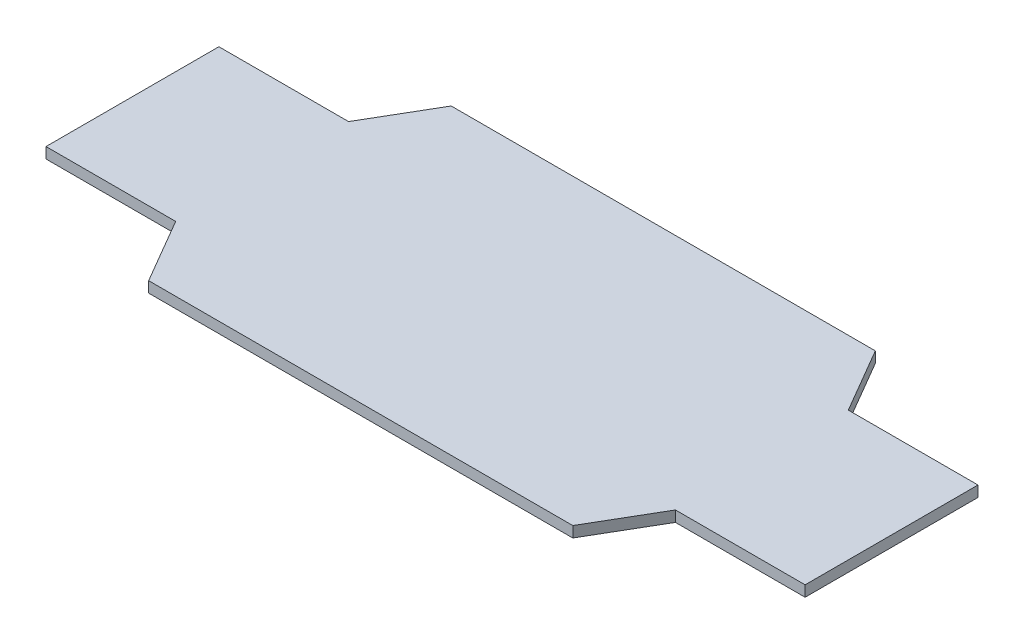
from build123d import *

# Parameters (mm, degrees)
BOSS_EXTRUDE1_DEPTH = 5.08


with BuildPart() as part:
    # Sketch1 → Boss-Extrude1 (new body)
    with BuildSketch(Plane(origin=(0, 0, 0), x_dir=(1, 0, 0), z_dir=(0, 1, 0))):
        Polygon((178.435, 40.64), (117.475, 40.64), (99.695, 71.12), (-99.695, 71.12), (-117.475, 40.64), (-178.435, 40.64), (-178.435, -40.64), (-117.475, -40.64), (-99.695, -71.12), (99.695, -71.12), (117.475, -40.64), (178.435, -40.64), align=None)
    extrude(amount=BOSS_EXTRUDE1_DEPTH)


solid = part.part
